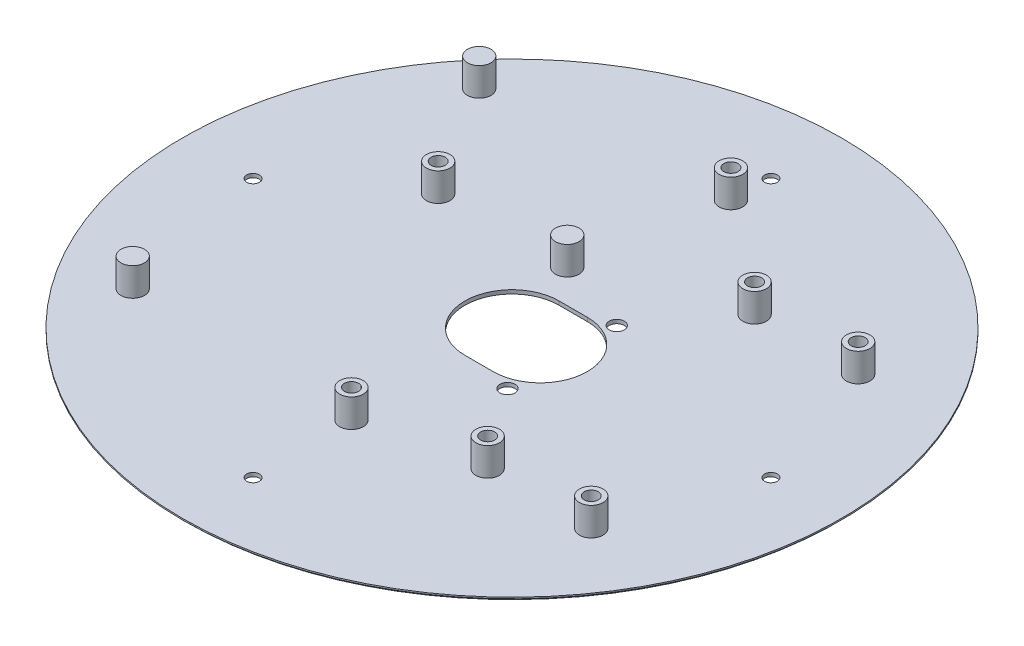
from build123d import *

# Parameters (mm, degrees)
SKIZZE1_R                            = 70
AUFSATZ_LINEAR_AUSTRAGEN1_DEPTH      = 0.8
SCHNITT_LINEAR_AUSTRAGEN1_REACH      = 2.8
SKIZZE2_R                            = 2.5
SKIZZE2_R_2                          = 1.5
AUFSATZ_LINEAR_AUSTRAGEN2_DEPTH      = 6
AUFSATZ_LINEAR_AUSTRAGEN2_DEPTH_BACK = 0.8
SKIZZE4_R                            = 1.5
SKIZZE4_R_2                          = 1.410083192
SCHNITT_LINEAR_AUSTRAGEN2_DEPTH      = 1.8
FASE1_SIZE                           = 0.5
SCHNITT_LINEAR_AUSTRAGEN3_REACH      = 8.8
SKIZZE5_R                            = 1.35
SKIZZE6_R                            = 1.6
SCHNITT_LINEAR_AUSTRAGEN4_DEPTH      = 4


with BuildPart() as part:
    # Skizze1 → Aufsatz-Linear austragen1 (new body)
    with BuildSketch(Plane(origin=(0, 0, 0), x_dir=(1, 0, 0), z_dir=(0, 1, 0))):
        Circle(SKIZZE1_R)
    extrude(amount=AUFSATZ_LINEAR_AUSTRAGEN1_DEPTH)

    # Skizze3 → Schnitt-Linear austragen1 (cut, up to next)
    with BuildSketch(Plane.XZ, mode=Mode.PRIVATE) as schnitt_linear_austragen1_sk1:
        with BuildLine():
            Line((6, -10), (0, -10))
            ThreePointArc((0, -10), (-10, 0), (0, 10))
            Line((0, 10), (6, 10))
            ThreePointArc((6, 10), (16, 0), (6, -10))
        make_face()
    schnitt_linear_austragen1_tool1 = extrude(schnitt_linear_austragen1_sk1.sketch, amount=-SCHNITT_LINEAR_AUSTRAGEN1_REACH, mode=Mode.PRIVATE) & part.part
    add(schnitt_linear_austragen1_tool1.solids().sort_by_distance((3, 0, 0))[0], mode=Mode.SUBTRACT)

    # Skizze2 → Aufsatz-Linear austragen2 (add, two sides)
    with BuildSketch(Plane(origin=(0, 0.8, 0), x_dir=(1, 0, 0), z_dir=(0, 1, 0))) as aufsatz_linear_austragen2_sk:
        with Locations((-47.533988615, 40.571841958)):
            Circle(SKIZZE2_R)
        with Locations((-5.293377745, 17.030303573)):
            Circle(SKIZZE2_R)
        with Locations((-47.533988615, -33.027520141)):
            Circle(SKIZZE2_R)
        with Locations((-32.533187453, 16.85488412)):
            Circle(SKIZZE2_R)
        with Locations((-32.533187453, 16.85488412)):
            Circle(SKIZZE2_R_2, mode=Mode.SUBTRACT)
        with Locations((-0.280707317, 46.779952313)):
            Circle(SKIZZE2_R)
        with Locations((-0.280707317, 46.779952313)):
            Circle(SKIZZE2_R_2, mode=Mode.SUBTRACT)
        with Locations((23.260650032, 28.271453094)):
            Circle(SKIZZE2_R)
        with Locations((23.260650032, 28.271453094)):
            Circle(SKIZZE2_R_2, mode=Mode.SUBTRACT)
        with Locations((45.260650032, 28.271453094)):
            Circle(SKIZZE2_R)
        with Locations((45.260650032, 28.271453094)):
            Circle(SKIZZE2_R_2, mode=Mode.SUBTRACT)
        with Locations((45.260650032, -28.428546906)):
            Circle(SKIZZE2_R)
        with Locations((45.260650032, -28.428546906)):
            Circle(SKIZZE2_R_2, mode=Mode.SUBTRACT)
        with Locations((23.260650032, -28.428546906)):
            Circle(SKIZZE2_R)
        with Locations((23.260650032, -28.428546906)):
            Circle(SKIZZE2_R_2, mode=Mode.SUBTRACT)
        with Locations((-0.152992521, -33.940171336)):
            Circle(SKIZZE2_R)
        with Locations((-0.152992521, -33.940171336)):
            Circle(SKIZZE2_R_2, mode=Mode.SUBTRACT)
    extrude(amount=AUFSATZ_LINEAR_AUSTRAGEN2_DEPTH)
    extrude(aufsatz_linear_austragen2_sk.sketch, amount=-AUFSATZ_LINEAR_AUSTRAGEN2_DEPTH_BACK)

    # Skizze4 → Schnitt-Linear austragen2 (cut, through all)
    with BuildSketch(Plane(origin=(0, 0.8, 0), x_dir=(1, 0, 0), z_dir=(0, 1, 0))):
        with Locations((-32.533187453, 16.85488412)):
            Circle(SKIZZE4_R)
        with Locations((23.260650032, 28.271453094)):
            Circle(SKIZZE4_R)
        with Locations((45.260650032, 28.271453094)):
            Circle(SKIZZE4_R)
        with Locations((45.260650032, -28.428546906)):
            Circle(SKIZZE4_R)
        with Locations((23.260650032, -28.428546906)):
            Circle(SKIZZE4_R)
        with Locations((-0.152992521, -33.940171336)):
            Circle(SKIZZE4_R)
        with Locations((-0.280707317, 46.779952313)):
            Circle(SKIZZE4_R_2)
    extrude(amount=-SCHNITT_LINEAR_AUSTRAGEN2_DEPTH, mode=Mode.SUBTRACT)

    # Fase1
    fase1_edges = [part.edges().sort_by_distance(p)[0] for p in [
        (-70, 0, 0),
    ]]
    chamfer(fase1_edges, length=FASE1_SIZE)

    # Skizze5 → Schnitt-Linear austragen3 (cut, up to next)
    with BuildSketch(Plane.XZ, mode=Mode.PRIVATE) as schnitt_linear_austragen3_sk1:
        with Locations((-55, 0)):
            Circle(SKIZZE5_R)
    schnitt_linear_austragen3_tool1 = extrude(schnitt_linear_austragen3_sk1.sketch, amount=-SCHNITT_LINEAR_AUSTRAGEN3_REACH, mode=Mode.PRIVATE) & part.part
    add(schnitt_linear_austragen3_tool1.solids().sort_by_distance((-55, 0, 0))[0], mode=Mode.SUBTRACT)
    # Skizze5 → Schnitt-Linear austragen3 (cut, up to next)
    with BuildSketch(Plane.XZ, mode=Mode.PRIVATE) as schnitt_linear_austragen3_sk2:
        with Locations((55, 0)):
            Circle(SKIZZE5_R)
    schnitt_linear_austragen3_tool2 = extrude(schnitt_linear_austragen3_sk2.sketch, amount=-SCHNITT_LINEAR_AUSTRAGEN3_REACH, mode=Mode.PRIVATE) & part.part
    add(schnitt_linear_austragen3_tool2.solids().sort_by_distance((55, 0, 0))[0], mode=Mode.SUBTRACT)
    # Skizze5 → Schnitt-Linear austragen3 (cut, up to next)
    with BuildSketch(Plane.XZ, mode=Mode.PRIVATE) as schnitt_linear_austragen3_sk3:
        with Locations((0, -55)):
            Circle(SKIZZE5_R)
    schnitt_linear_austragen3_tool3 = extrude(schnitt_linear_austragen3_sk3.sketch, amount=-SCHNITT_LINEAR_AUSTRAGEN3_REACH, mode=Mode.PRIVATE) & part.part
    add(schnitt_linear_austragen3_tool3.solids().sort_by_distance((0, 0, -55))[0], mode=Mode.SUBTRACT)
    # Skizze5 → Schnitt-Linear austragen3 (cut, up to next)
    with BuildSketch(Plane.XZ, mode=Mode.PRIVATE) as schnitt_linear_austragen3_sk4:
        with Locations((0, 55)):
            Circle(SKIZZE5_R)
    schnitt_linear_austragen3_tool4 = extrude(schnitt_linear_austragen3_sk4.sketch, amount=-SCHNITT_LINEAR_AUSTRAGEN3_REACH, mode=Mode.PRIVATE) & part.part
    add(schnitt_linear_austragen3_tool4.solids().sort_by_distance((0, 0, 55))[0], mode=Mode.SUBTRACT)

    # Skizze6 → Schnitt-Linear austragen4 (cut)
    with BuildSketch(Plane(origin=(0, 0, 0), x_dir=(-1, 0, 0), z_dir=(0, -1, 0))):
        with Locations((-10.644187298, 11.605236936)):
            Circle(SKIZZE6_R)
        with Locations((-10.644187298, -11.605236936)):
            Circle(SKIZZE6_R)
    extrude(amount=-SCHNITT_LINEAR_AUSTRAGEN4_DEPTH, mode=Mode.SUBTRACT)


solid = part.part
